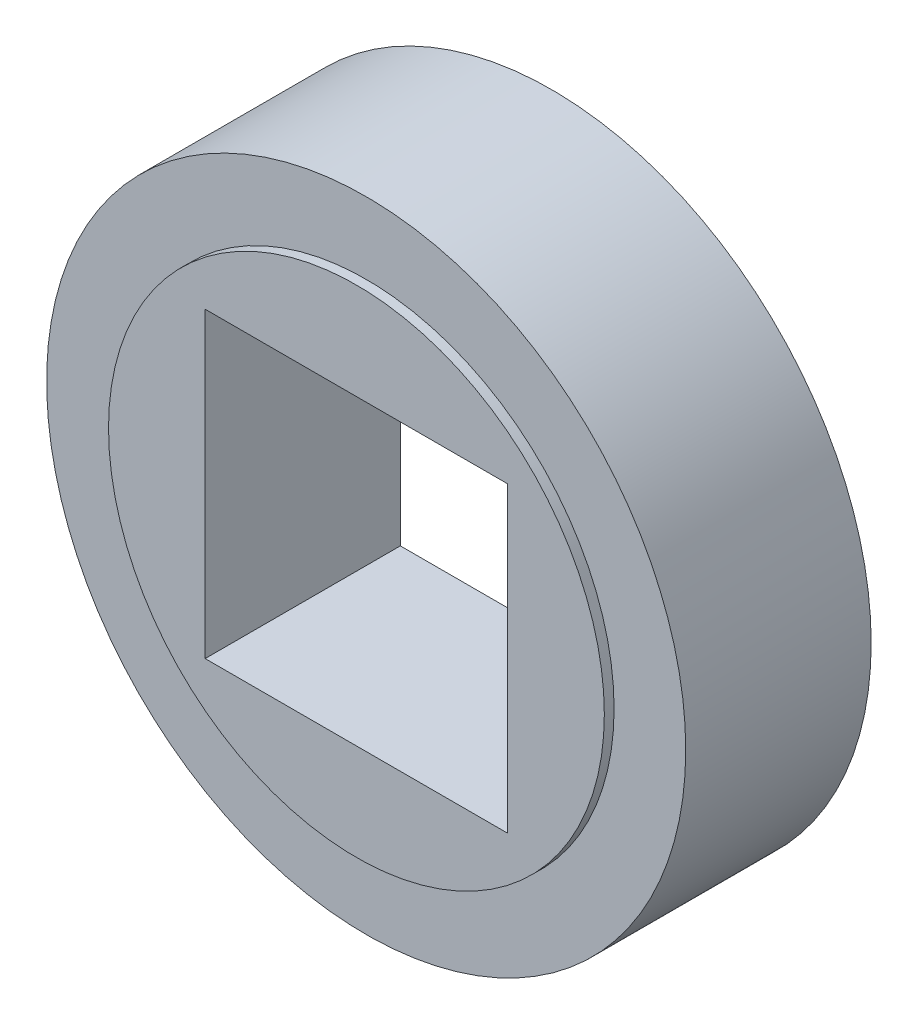
from build123d import *

# Parameters (mm, degrees)
SKETCH1_R           = 32.7406
SKETCH1_W           = 31
SKETCH1_H           = 31
BOSS_EXTRUDE1_DEPTH = 20
SKETCH2_R           = 32.7406
SKETCH2_R_2         = 25.4
CUT_EXTRUDE1_DEPTH  = 1


with BuildPart() as part:
    # Sketch1 → Boss-Extrude1 (new body)
    with BuildSketch(Plane.XY):
        Circle(SKETCH1_R)
        Rectangle(SKETCH1_W, SKETCH1_H, mode=Mode.SUBTRACT)
    extrude(amount=BOSS_EXTRUDE1_DEPTH)

    # Sketch2 → Cut-Extrude1 (cut)
    with BuildSketch(Plane.XY.offset(20)):
        Circle(SKETCH2_R)
        Circle(SKETCH2_R_2, mode=Mode.SUBTRACT)
    extrude(amount=-CUT_EXTRUDE1_DEPTH, mode=Mode.SUBTRACT)


solid = part.part
